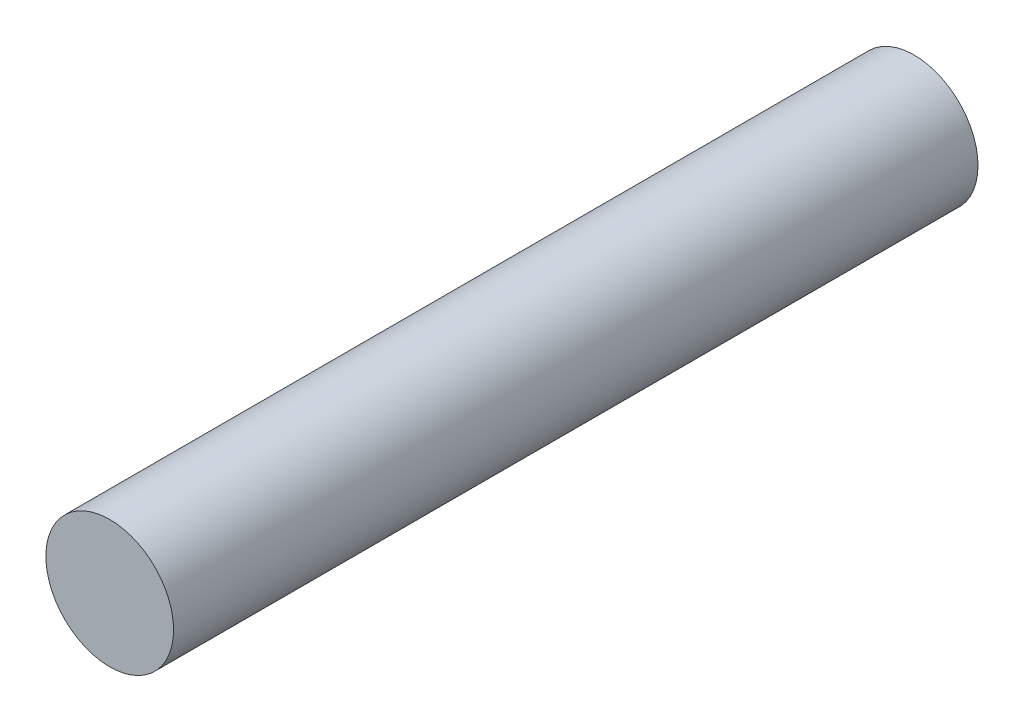
from build123d import *

# Parameters (mm, degrees)
SKETCH1_R           = 1.5875
BOSS_EXTRUDE1_DEPTH = 20


with BuildPart() as part:
    # Sketch1 → Boss-Extrude1 (new body)
    with BuildSketch(Plane.XY):
        Circle(SKETCH1_R)
    extrude(amount=BOSS_EXTRUDE1_DEPTH)


solid = part.part
